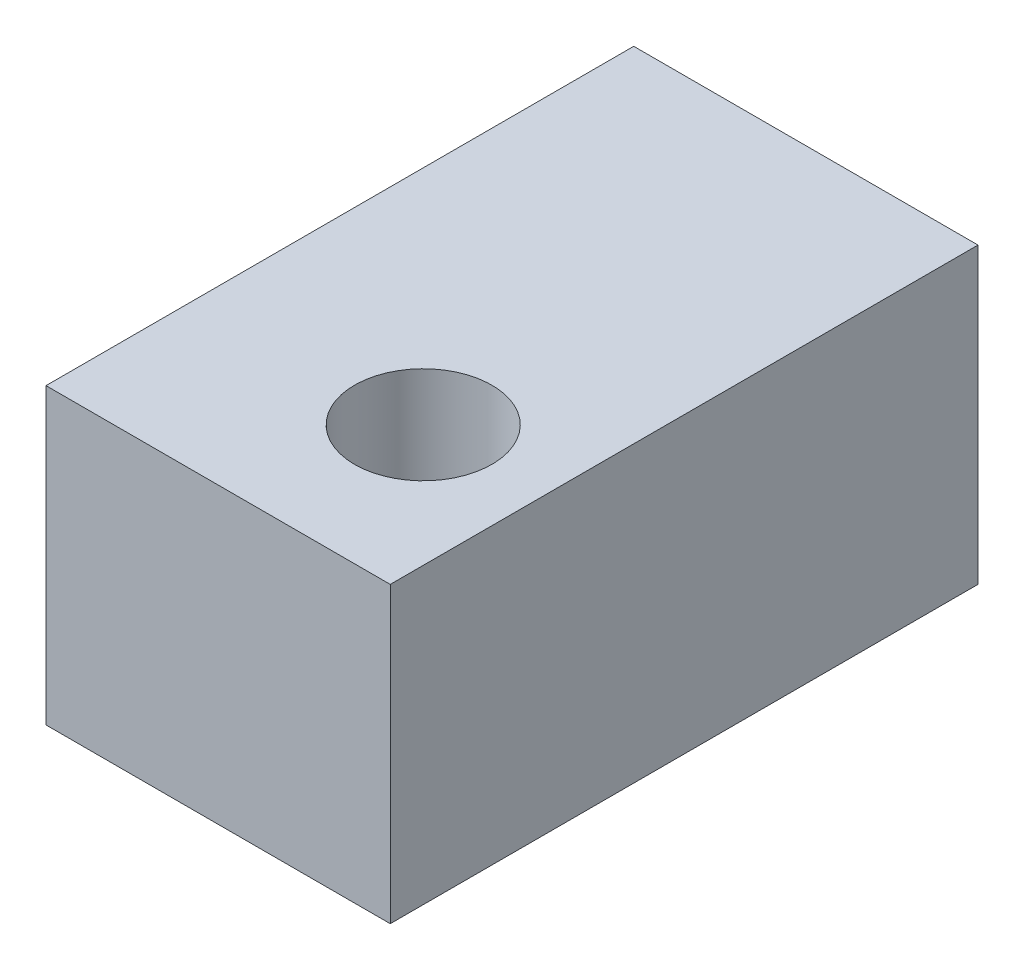
from build123d import *

# Parameters (mm, degrees)
ESQUISSE1_W             = 205
ESQUISSE1_H             = 175
BOSS_EXTRU_1_DEPTH      = 350
ESQUISSE2_R             = 40.885164142
ENL_V_MAT_EXTRU_1_DEPTH = 100


with BuildPart() as part:
    # Esquisse1 → Boss.-Extru.1 (new body)
    with BuildSketch(Plane.XY):
        with Locations((102.5, 87.5)):
            Rectangle(ESQUISSE1_W, ESQUISSE1_H)
    extrude(amount=BOSS_EXTRU_1_DEPTH)

    # Esquisse2 → Enlèv. mat.-Extru.1 (cut)
    with BuildSketch(Plane(origin=(0, 175, 0), x_dir=(1, 0, 0), z_dir=(0, 1, 0))):
        with Locations((132.503028047, -257.884998031)):
            Circle(ESQUISSE2_R)
    extrude(amount=-ENL_V_MAT_EXTRU_1_DEPTH, mode=Mode.SUBTRACT)


solid = part.part
